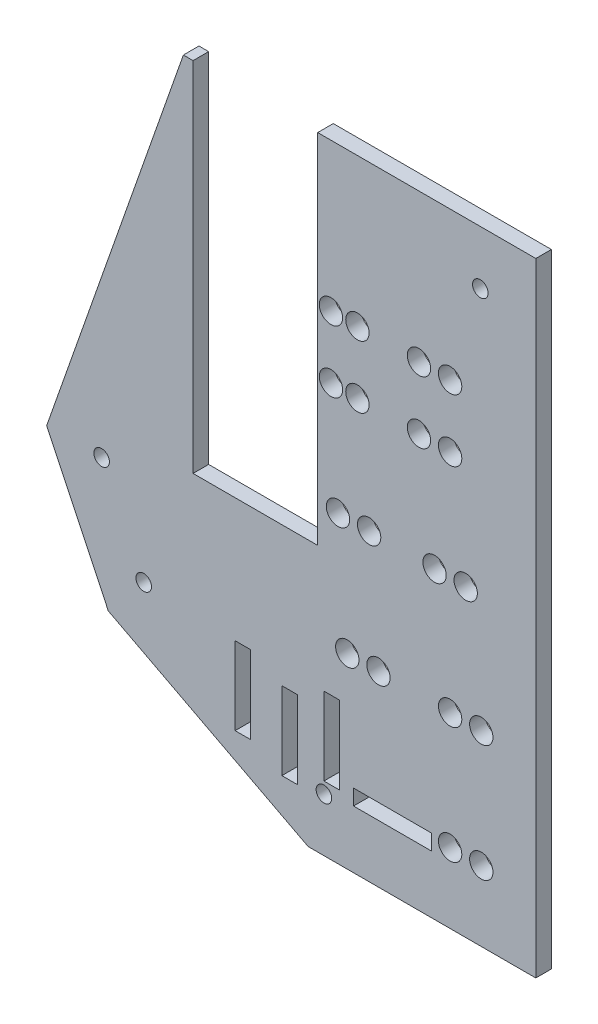
from build123d import *

# Parameters (mm, degrees)
BOSS_EXTRUDE1_DEPTH = 2.54
SKETCH4_R           = 1.905
SKETCH4_W           = 20.32
SKETCH4_H           = 50.8
CUT_EXTRUDE2_DEPTH  = 25.4
SKETCH5_W           = 20.32
SKETCH5_H           = 7.493
CUT_EXTRUDE3_DEPTH  = 5.08
SKETCH6_R           = 1.27
CUT_EXTRUDE4_DEPTH  = 5.08
SKETCH8_W           = 12.7
SKETCH8_H           = 2.54
SKETCH8_W_2         = 2.54
SKETCH8_H_2         = 12.7
CUT_EXTRUDE5_DEPTH  = 5.08


with BuildPart() as part:
    # Sketch1 → Boss-Extrude1 (new body)
    with BuildSketch(Plane.XY):
        Polygon((-4.120444444, 6.35), (53.34, 6.35), (53.34, -95.25), (16.22499019, -95.25), (-16.356614113, -78.274710363), (-26.416, -57.15), align=None)
    extrude(amount=BOSS_EXTRUDE1_DEPTH)

    # Sketch4 → Cut-Extrude2 (cut)
    with BuildSketch(Plane(origin=(0, 0, 0), x_dir=(-1, 0, 0), z_dir=(0, 0, -1))):
        with Locations((-39.37, -17.78)):
            Circle(SKETCH4_R)
        with Locations((-34.29, -17.78)):
            Circle(SKETCH4_R)
        with Locations((-39.37, -27.94)):
            Circle(SKETCH4_R)
        with Locations((-34.29, -27.94)):
            Circle(SKETCH4_R)
        with Locations((-41.91, -45.72)):
            Circle(SKETCH4_R)
        with Locations((-36.83, -45.72)):
            Circle(SKETCH4_R)
        with Locations((-44.45, -64.77)):
            Circle(SKETCH4_R)
        with Locations((-39.37, -64.77)):
            Circle(SKETCH4_R)
        with Locations((-44.45, -83.82)):
            Circle(SKETCH4_R)
        with Locations((-39.37, -83.82)):
            Circle(SKETCH4_R)
        with Locations((-24.257, -17.78)):
            Circle(SKETCH4_R)
        with Locations((-19.939, -17.78)):
            Circle(SKETCH4_R)
        with Locations((-24.257, -27.94)):
            Circle(SKETCH4_R)
        with Locations((-19.939, -27.94)):
            Circle(SKETCH4_R)
        with Locations((-26.162, -45.72)):
            Circle(SKETCH4_R)
        with Locations((-21.082, -45.72)):
            Circle(SKETCH4_R)
        with Locations((-27.686, -64.77)):
            Circle(SKETCH4_R)
        with Locations((-22.606, -64.77)):
            Circle(SKETCH4_R)
        with Locations((-7.62, -26.543)):
            Rectangle(SKETCH4_W, SKETCH4_H)
    extrude(amount=-CUT_EXTRUDE2_DEPTH, mode=Mode.SUBTRACT)

    # Sketch5 → Cut-Extrude3 (cut)
    with BuildSketch(Plane.XY.offset(2.54)):
        with Locations((7.62, 2.6035)):
            Rectangle(SKETCH5_W, SKETCH5_H)
    extrude(amount=-CUT_EXTRUDE3_DEPTH, mode=Mode.SUBTRACT)

    # Sketch6 → Cut-Extrude4 (cut)
    with BuildSketch(Plane.XY.offset(2.54)):
        with Locations((1.6002, -2.4384)):
            Circle(SKETCH6_R)
        with Locations((44.2976, -2.4384)):
            Circle(SKETCH6_R)
        with Locations((-17.4498, -57.15)):
            Circle(SKETCH6_R)
        with Locations((-10.5918, -71.3486)):
            Circle(SKETCH6_R)
        with Locations((18.796, -86.5378)):
            Circle(SKETCH6_R)
    extrude(amount=-CUT_EXTRUDE4_DEPTH, mode=Mode.SUBTRACT)

    # Sketch8 → Cut-Extrude5 (cut)
    with BuildSketch(Plane.XY.offset(2.54)):
        with Locations((29.972, -84.5566)):
            Rectangle(SKETCH8_W, SKETCH8_H)
        with Locations((20.066, -78.359)):
            Rectangle(SKETCH8_W_2, SKETCH8_H_2)
        with Locations((13.208, -81.026)):
            Rectangle(SKETCH8_W_2, SKETCH8_H_2)
        with Locations((5.588, -78.486)):
            Rectangle(SKETCH8_W_2, SKETCH8_H_2)
    extrude(amount=-CUT_EXTRUDE5_DEPTH, mode=Mode.SUBTRACT)


solid = part.part
